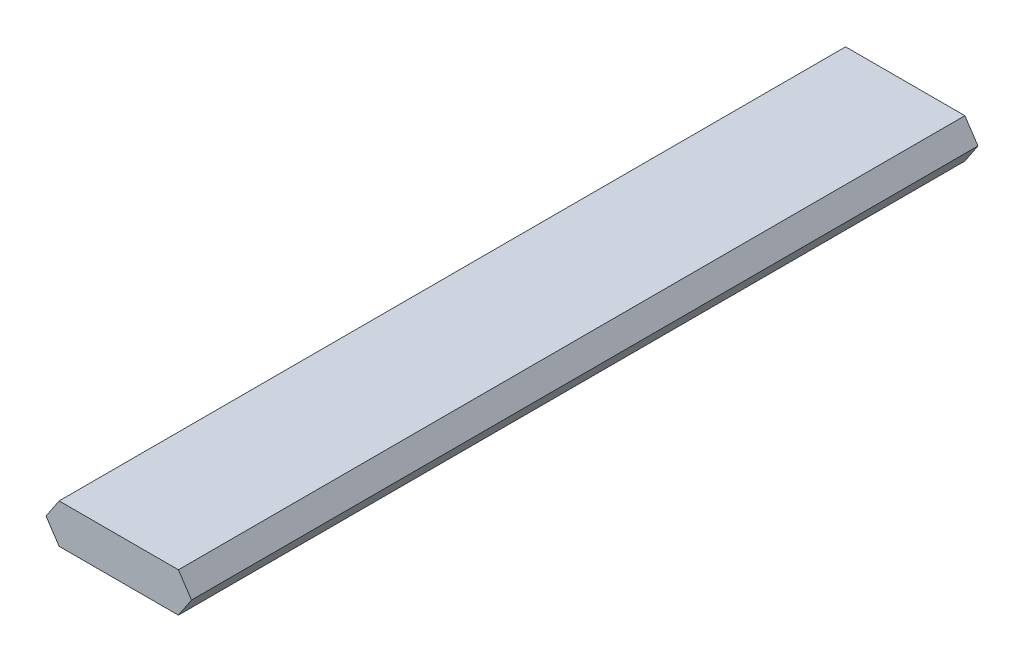
from build123d import *

# Parameters (mm, degrees)
BOSS_EXTRU_1_DEPTH = 120


with BuildPart() as part:
    # Esquisse1 → Boss.-Extru.1 (new body)
    with BuildSketch(Plane.XY):
        Polygon((0, 0), (2, 3), (20.2, 3), (22.2, 0), (20.2, -3), (2, -3), align=None)
    extrude(amount=BOSS_EXTRU_1_DEPTH)


solid = part.part
